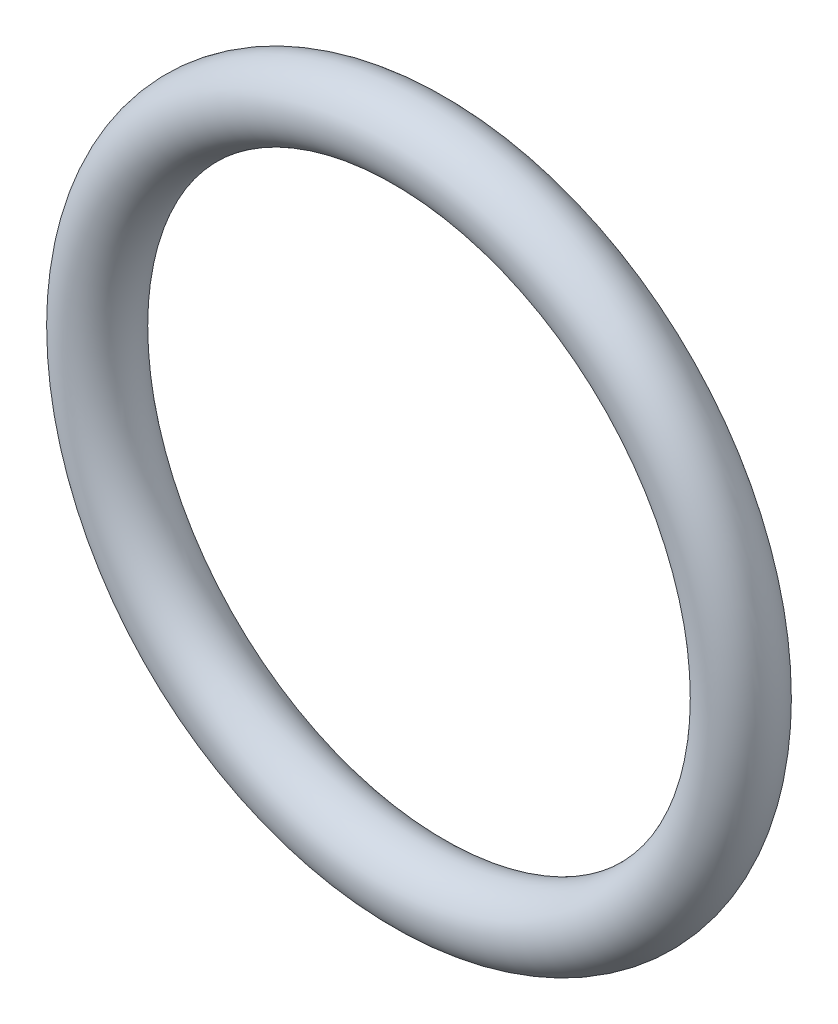
from build123d import *

# Parameters (mm, degrees)
SKETCH1_R = 0.5


with BuildPart() as part:
    # Sketch1 → Revolve1 (revolve)
    with BuildSketch(Plane(origin=(0, 0, 0), x_dir=(0, -1, 0), z_dir=(1, 0, 0))):
        with Locations((4.5, 0)):
            Circle(SKETCH1_R)
    revolve(axis=Axis((0, 0, 0.5), (0, 0, -1)))


solid = part.part
